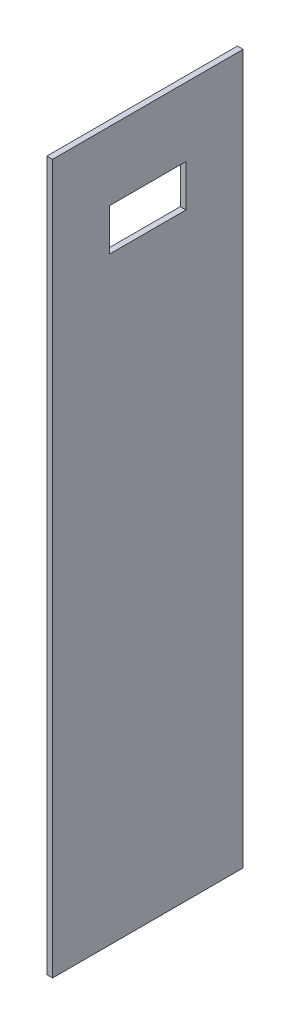
from build123d import *

# Parameters (mm, degrees)
SKETCH1_W           = 1.5
SKETCH1_H           = 50
BOSS_EXTRUDE1_DEPTH = 93
SKETCH3_W           = 20
SKETCH3_H           = 11
SWITCH_DEPTH        = 2.5


with BuildPart() as part:
    # Sketch1 → Boss-Extrude1 (new body, symmetric)
    with BuildSketch(Plane(origin=(0, 0, 0), x_dir=(1, 0, 0), z_dir=(0, 1, 0))):
        Rectangle(SKETCH1_W, SKETCH1_H)
    extrude(amount=BOSS_EXTRUDE1_DEPTH, both=True)

    # Sketch3 → Switch (cut, through all)
    with BuildSketch(Plane.ZY.offset(0.75)):
        with Locations((0, 69.5)):
            Rectangle(SKETCH3_W, SKETCH3_H)
    extrude(amount=-SWITCH_DEPTH, mode=Mode.SUBTRACT)


solid = part.part
